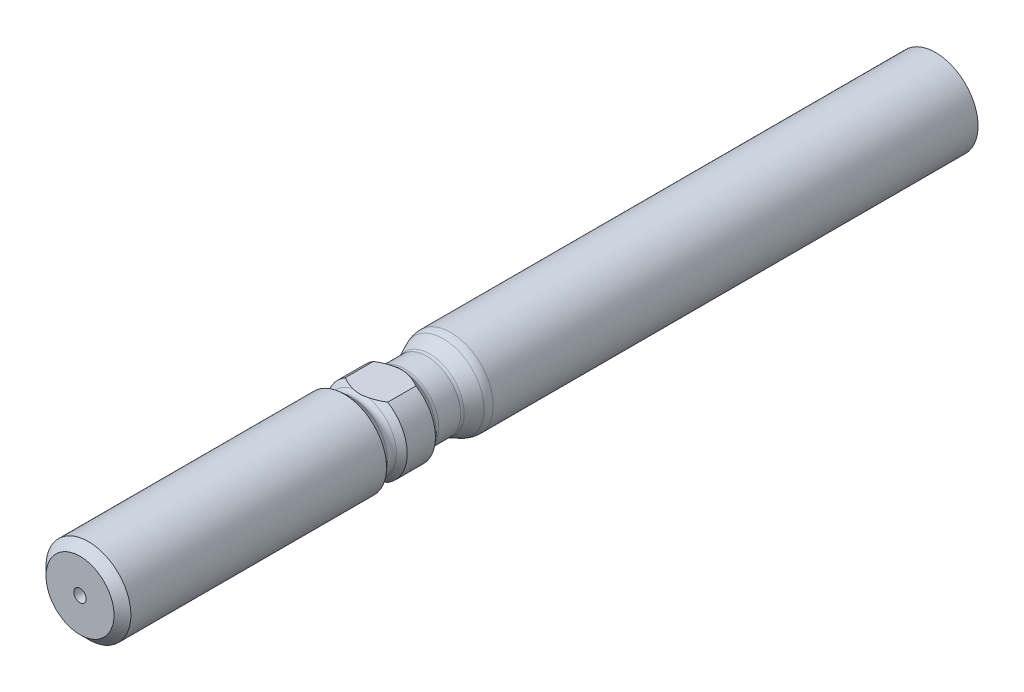
from build123d import *

# Parameters (mm, degrees)
SKETCH2_W               = 5
SKETCH2_H               = 8
CUT_EXTRUDE3_DEPTH      = 5.7625
CUT_EXTRUDE3_DEPTH_BACK = 5.7625
SKETCH4_R               = 0.7
CUT_EXTRUDE4_DEPTH      = 10


with BuildPart() as part:
    # Sketch1 → Revolve1 (revolve)
    with BuildSketch(Plane(origin=(0, 0, 0), x_dir=(1, 0, 0), z_dir=(0, 1, 0))):
        with BuildLine():
            Line((4.7625, 0), (4.7625, -42.324998204))
            ThreePointArc((4.7625, -42.324998204), (4.715092014, -42.757877432), (4.575115574, -43.170234727))
            Line((4.575115574, -43.170234727), (3.86526916, -44.692505275))
            ThreePointArc((3.86526916, -44.692505275), (3.812777995, -44.847139261), (3.795, -45.009468972))
            Line((3.795, -45.009468972), (3.795, -47.469468972))
            ThreePointArc((3.795, -47.469468972), (3.84481468, -47.738244934), (3.987641381, -47.971316926))
            Line((3.987641381, -47.971316926), (4.57, -48.618091697))
            Line((4.57, -48.618091697), (4.57, -51.788091697))
            Line((4.57, -51.788091697), (3.995209933, -52.426460739))
            ThreePointArc((3.995209933, -52.426460739), (3.8, -52.935), (3.995209933, -53.443539261))
            Line((3.995209933, -53.443539261), (4.7625, -54.295701212))
            Line((4.7625, -54.295701212), (4.7625, -82.9725))
            Line((4.7625, -82.9725), (3.815, -83.92))
            Line((3.815, -83.92), (0, -83.92))
            Line((0, -83.92), (0, 0))
            Line((0, 0), (0, 12.06))
            Line((0, 12.06), (4.7625, 12.06))
            Line((4.7625, 12.06), (4.7625, 0))
        make_face()
    revolve(axis=Axis((0, 0, 0), (0, 0, 1)))

    # Sketch2 → Cut-Extrude3 (cut, two sides)
    with BuildSketch(Plane(origin=(0, 0, 0), x_dir=(0, 0, -1), z_dir=(1, 0, 0))) as cut_extrude3_sk:
        with Locations((-50.25, 7.9)):
            Rectangle(SKETCH2_W, SKETCH2_H)
        with Locations((-50.25, -7.9)):
            Rectangle(SKETCH2_W, SKETCH2_H)
    extrude(amount=CUT_EXTRUDE3_DEPTH, mode=Mode.SUBTRACT)
    extrude(cut_extrude3_sk.sketch, amount=-CUT_EXTRUDE3_DEPTH_BACK, mode=Mode.SUBTRACT)

    # Sketch4 → Cut-Extrude4 (cut)
    with BuildSketch(Plane.XY.offset(83.92)):
        Circle(SKETCH4_R)
    extrude(amount=-CUT_EXTRUDE4_DEPTH, mode=Mode.SUBTRACT)


solid = part.part
